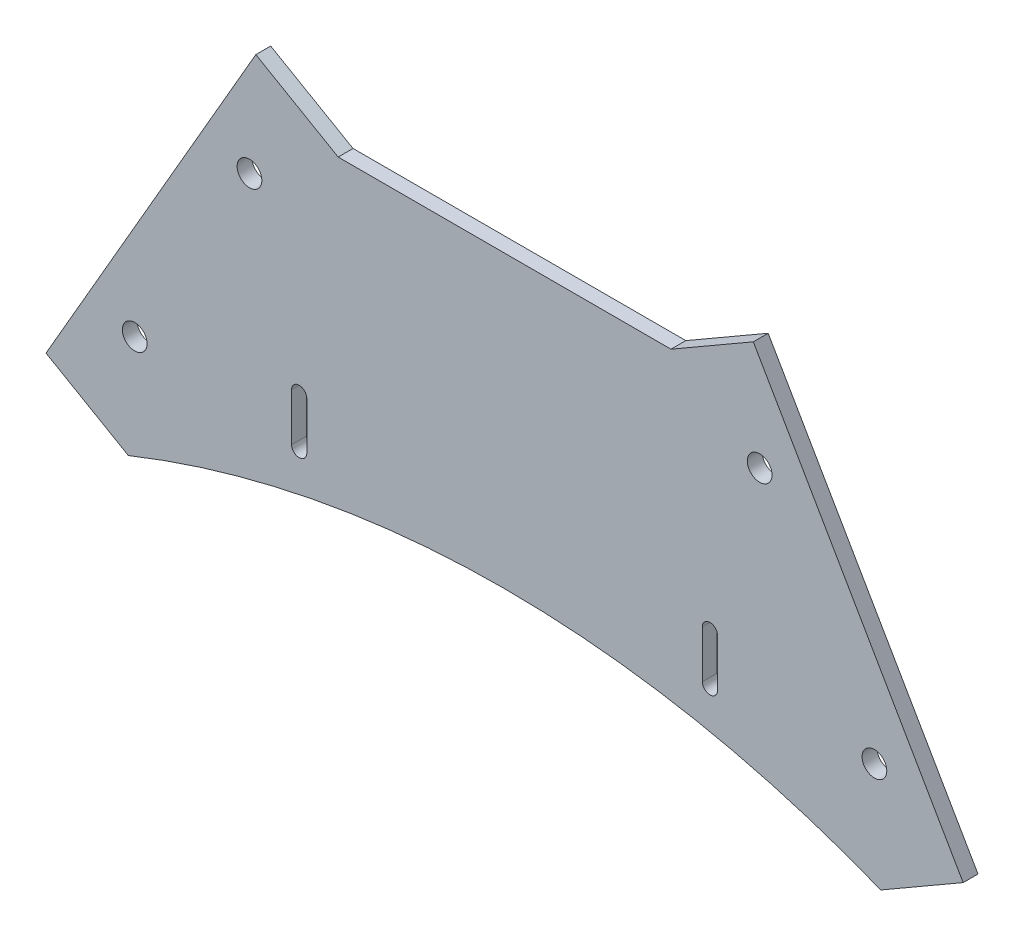
from build123d import *

# Parameters (mm, degrees)
MODEL_R             = 2.6
BOSS_EXTRUDE1_DEPTH = 3.125


with BuildPart() as part:
    # Model → Boss-Extrude1 (new body)
    with BuildSketch(Plane.XY):
        with BuildLine():
            Line((175.590993043, 0), (192.911501119, 10))
            Line((192.911501119, 10), (148.776258635, 86.444482386))
            Line((148.776258635, 86.444482386), (131.455750559, 76.444482386))
            Line((131.455750559, 76.444482386), (61.455750559, 76.444482386))
            Line((61.455750559, 76.444482386), (44.135242484, 86.444482386))
            Line((44.135242484, 86.444482386), (0, 10))
            Line((0, 10), (17.320508076, 0))
            ThreePointArc((17.320508076, 0), (96.455750559, 15.314685), (175.590993043, 0))
        make_face()
        with Locations((42.795496522, 64.123974311)):
            Circle(MODEL_R, mode=Mode.SUBTRACT)
        with Locations((18.660254038, 22.320508076)):
            Circle(MODEL_R, mode=Mode.SUBTRACT)
        with Locations((150.116004597, 64.123974311)):
            Circle(MODEL_R, mode=Mode.SUBTRACT)
        with Locations((174.251247081, 22.320508076)):
            Circle(MODEL_R, mode=Mode.SUBTRACT)
        with BuildLine():
            Line((54.855750559, 29.174833766), (54.855750559, 19.174833766))
            ThreePointArc((54.855750559, 19.174833766), (53.255750559, 17.574833766), (51.655750559, 19.174833766))
            Line((51.655750559, 19.174833766), (51.655750559, 29.174833766))
            ThreePointArc((51.655750559, 29.174833766), (53.255750559, 30.774833766), (54.855750559, 29.174833766))
        make_face(mode=Mode.SUBTRACT)
        with BuildLine():
            Line((141.255750559, 29.174833766), (141.255750559, 19.174833766))
            ThreePointArc((141.255750559, 19.174833766), (139.655750559, 17.574833766), (138.055750559, 19.174833766))
            Line((138.055750559, 19.174833766), (138.055750559, 29.174833766))
            ThreePointArc((138.055750559, 29.174833766), (139.655750559, 30.774833766), (141.255750559, 29.174833766))
        make_face(mode=Mode.SUBTRACT)
    extrude(amount=BOSS_EXTRUDE1_DEPTH)


solid = part.part
